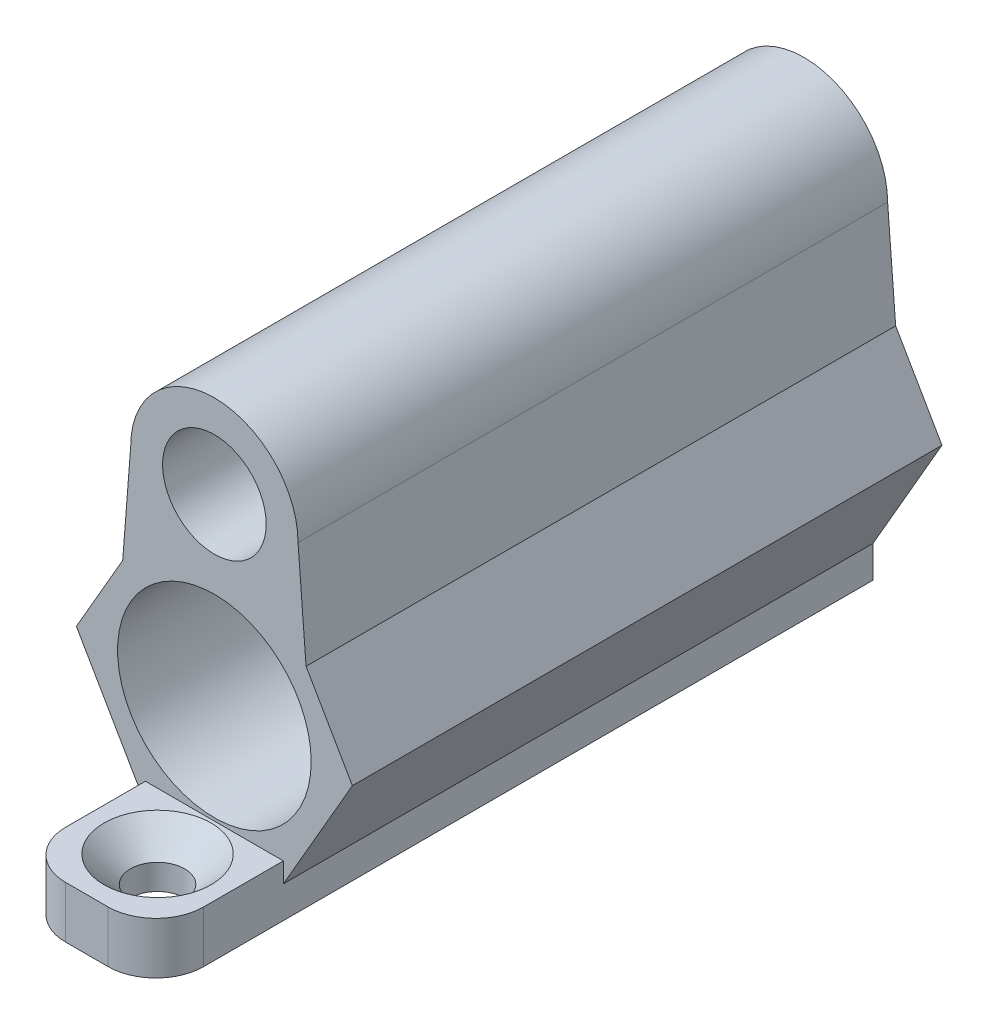
from build123d import *

# Parameters (mm, degrees)
SKETCH1_R           = 2.44
BOSS_EXTRUDE2_DEPTH = 37
SKETCH8_R           = 3.25
SKETCH8_R_2         = 6.075
CUT_EXTRUDE1_DEPTH  = 33
BOSS_EXTRUDE4_DEPTH = 37
SKETCH18_W          = 8.660254038
SKETCH18_H          = 37
BOSS_EXTRUDE5_DEPTH = 2
SKETCH19_W          = 8.660254038
SKETCH19_H          = 3.245908706
BOSS_EXTRUDE6_DEPTH = 8
FILLET4_R           = 3


with BuildPart() as part:
    # Sketch1 → Boss-Extrude2 (new body)
    with BuildSketch(Plane.XY):
        with BuildLine():
            ThreePointArc((3.987455097, 4.316546763), (0, 8), (-3.987455097, 4.316546763))
            Line((-3.987455097, 4.316546763), (-4.330127019, 0))
            Line((-4.330127019, 0), (-8.660254038, -7.5))
            Line((-8.660254038, -7.5), (-4.330127019, -15))
            Line((-4.330127019, -15), (4.330127019, -15))
            Line((4.330127019, -15), (8.660254038, -7.5))
            Line((8.660254038, -7.5), (4.330127019, 0))
            Line((4.330127019, 0), (3.987455097, 4.316546763))
        make_face()
        with Locations((0, 4)):
            Circle(SKETCH1_R, mode=Mode.SUBTRACT)
        with Locations((0, -7.5)):
            Circle(SKETCH1_R, mode=Mode.SUBTRACT)
    extrude(amount=BOSS_EXTRUDE2_DEPTH)

    # Sketch8 → Cut-Extrude1 (cut)
    with BuildSketch(Plane.XY.offset(37)):
        with Locations((0, 4)):
            Circle(SKETCH8_R)
        with Locations((0, -7.5)):
            Circle(SKETCH8_R_2)
    extrude(amount=-CUT_EXTRUDE1_DEPTH, mode=Mode.SUBTRACT)

    # Sketch15 → Boss-Extrude4 (add)
    with BuildSketch(Plane.XY.offset(37)):
        with BuildLine():
            ThreePointArc((5.25, 4), (0, 9.25), (-5.25, 4))
            ThreePointArc((-5.25, 4), (-4.995467041, 2.385128786), (-4.256548938, 0.926843456))
            Line((-4.256548938, 0.926843456), (-3.987455097, 4.316546763))
            ThreePointArc((-3.987455097, 4.316546763), (0, 8), (3.987455097, 4.316546763))
            Line((3.987455097, 4.316546763), (4.256548938, 0.926843456))
            ThreePointArc((4.256548938, 0.926843456), (4.995467041, 2.385128786), (5.25, 4))
        make_face()
        with BuildLine():
            ThreePointArc((-4.256548938, 0.926843456), (-4.995467041, 2.385128786), (-5.25, 4))
            Line((-5.25, 4), (-5.753496857, -2.465348878))
            Line((-5.753496857, -2.465348878), (-4.330127019, 0))
            Line((-4.330127019, 0), (-4.256548938, 0.926843456))
        make_face()
        with BuildLine():
            Line((5.753496857, -2.465348878), (5.25, 4))
            ThreePointArc((5.25, 4), (4.995467041, 2.385128786), (4.256548938, 0.926843456))
            Line((4.256548938, 0.926843456), (4.330127019, 0))
            Line((4.330127019, 0), (5.753496857, -2.465348878))
        make_face()
    extrude(amount=-BOSS_EXTRUDE4_DEPTH)

    # Sketch18 → Boss-Extrude5 (add)
    with BuildSketch(Plane.XZ.offset(15)):
        with Locations((0, 18.5)):
            Rectangle(SKETCH18_W, SKETCH18_H)
    extrude(amount=BOSS_EXTRUDE5_DEPTH)

    # Sketch19 → Boss-Extrude6 (add)
    with BuildSketch(Plane.XY.offset(37)):
        with Locations((0, -15.377045647)):
            Rectangle(SKETCH19_W, SKETCH19_H)
    extrude(amount=BOSS_EXTRUDE6_DEPTH)

    # Fillet4
    fillet4_edges = [part.edges().sort_by_distance(p)[0] for p in [
        (-4.330127019, -15.377045647, 45),
        (4.330127019, -15.377045647, 45),
    ]]
    fillet(fillet4_edges, radius=FILLET4_R)

    # Sketch21 → CSK for M3 Hex Socket Countersunk Cap Screw1 (revolve, cut)
    with BuildSketch(Plane(origin=(0, -13.754091294, 40.565360139), x_dir=(0, 0, 1), z_dir=(1, 0, 0))):
        Polygon((0, 0), (0, 3.245908706), (1.7, 3.245908706), (1.7, 1.66), (3.36, 0), align=None)
    revolve(axis=Axis((0, -7.404091294, 40.565360139), (0, -1, 0)), mode=Mode.SUBTRACT)


solid = part.part
